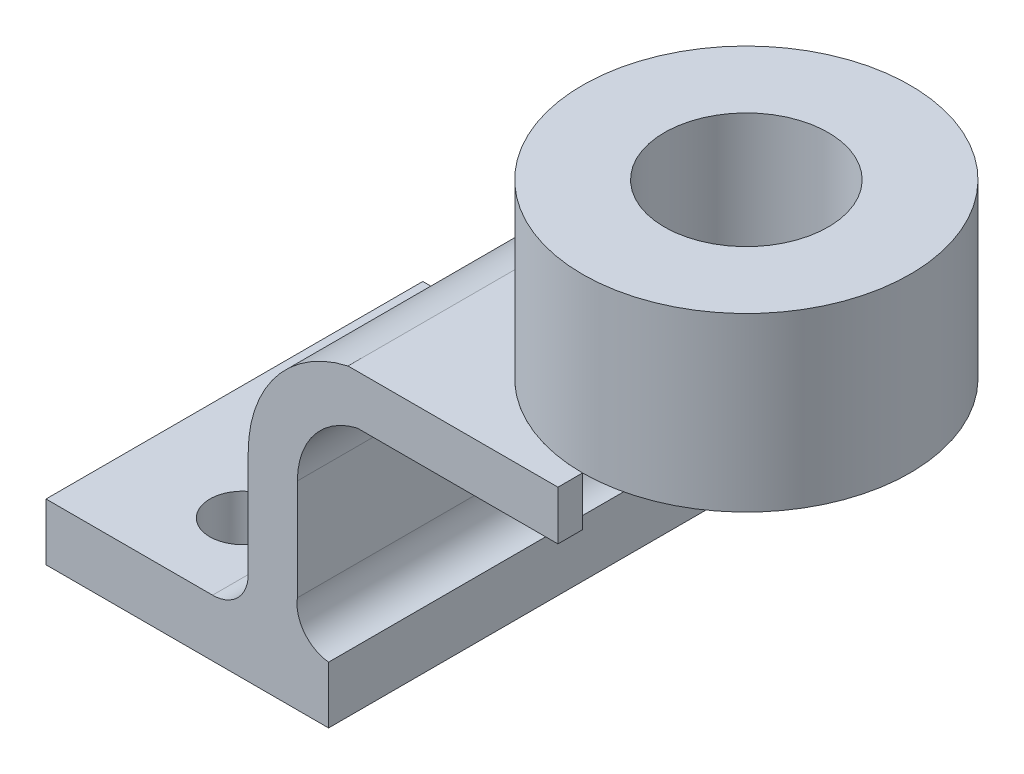
from build123d import *

# Parameters (mm, degrees)
BOSS_EXTRUDE4_DEPTH      = 46
BOSS_EXTRUDE4_DEPTH_BACK = 46
BOSS_EXTRUDE7_DEPTH      = 42
BOSS_EXTRUDE7_DEPTH_BACK = 18
SKETCH4_R                = 20
CUT_EXTRUDE6_DEPTH       = 49
SKETCH3_R                = 8
CUT_EXTRUDE7_DEPTH       = 49


with BuildPart() as part:
    # Sketch1 → Boss-Extrude4 (new, two sides: drawn at the far end of the back side and taken through both)
    with BuildSketch(Plane.XY.offset(-BOSS_EXTRUDE4_DEPTH_BACK)):
        with BuildLine():
            Line((-83.24312297, -25.479382505), (-14.24312297, -25.479382505))
            Line((-14.24312297, -25.479382505), (-14.24312297, -11.557434351))
            ThreePointArc((-14.24312297, -11.557434351), (-20.155754423, -8.289544205), (-21.866972477, -1.754251597))
            Line((-21.866972477, -1.754251597), (-21.866972477, 22.947247706))
            ThreePointArc((-21.866972477, 22.947247706), (-17.780772391, 34.725544597), (-7.278061456, 41.442565649))
            Line((-7.278061456, 41.442565649), (87.990821984, 41.442565649))
            Line((87.990821984, 41.442565649), (87.990821984, 53.442590356))
            Line((87.990821984, 53.442590356), (-9.495412844, 53.442590356))
            ThreePointArc((-9.495412844, 53.442590356), (-27.025554627, 42.466077348), (-33.866972477, 22.947247706))
            Line((-33.866972477, 22.947247706), (-33.866972477, -2.851012333))
            ThreePointArc((-33.866972477, -2.851012333), (-36.417024446, -9.007382382), (-42.573394495, -11.557434351))
            Line((-42.573394495, -11.557434351), (-83.24312297, -11.557434351))
            Line((-83.24312297, -11.557434351), (-83.24312297, -25.479382505))
        make_face()
    extrude(amount=BOSS_EXTRUDE4_DEPTH + BOSS_EXTRUDE4_DEPTH_BACK)

    # Sketch4 → Boss-Extrude7 (add, two sides: drawn at the far end of the back side and taken through both)
    with BuildSketch(Plane(origin=(0, 53.442590356, 0), x_dir=(1, 0, 0), z_dir=(0, 1, 0)).offset(-BOSS_EXTRUDE7_DEPTH_BACK)):
        with BuildLine():
            ThreePointArc((41.75687703, -40), (70.041148278, -28.284271247), (81.75687703, 0))
            ThreePointArc((81.75687703, 0), (70.041148278, 28.284271247), (41.75687703, 40))
            ThreePointArc((41.75687703, 40), (1.75687703, 0), (41.75687703, -40))
        make_face()
        with Locations((41.75687703, 0)):
            Circle(SKETCH4_R, mode=Mode.SUBTRACT)
    extrude(amount=BOSS_EXTRUDE7_DEPTH + BOSS_EXTRUDE7_DEPTH_BACK)

    # Sketch5 → Cut-Extrude6 (cut)
    with BuildSketch(Plane(origin=(0, 53.442590356, 0), x_dir=(1, 0, 0), z_dir=(0, 1, 0))):
        with BuildLine():
            Line((41.75687703, 46), (41.75687703, 40))
            ThreePointArc((41.75687703, 40), (1.75687703, 0), (41.75687703, -40))
            Line((41.75687703, -40), (41.75687703, -46))
            Line((41.75687703, -46), (87.990821984, -46))
            Line((87.990821984, -46), (87.990821984, 46))
            Line((87.990821984, 46), (41.75687703, 46))
        make_face()
    extrude(amount=-CUT_EXTRUDE6_DEPTH, mode=Mode.SUBTRACT)


with BuildPart() as cut_extrude6_piece_1:
    # of the separate pieces the step leaves, piece 1, a body of its own (cut_extrude6_pieces)
    add(part.part.solids().sort_by_distance((-42.573394495, -11.557434351, 46))[0])

    # Sketch3 → Cut-Extrude7 (cut)
    with BuildSketch(Plane(origin=(0, -11.557434351, 0), x_dir=(1, 0, 0), z_dir=(0, 1, 0))):
        with Locations((-55.24312297, 26)):
            Circle(SKETCH3_R)
        with Locations((-55.24312297, -26)):
            Circle(SKETCH3_R)
    extrude(amount=-CUT_EXTRUDE7_DEPTH, mode=Mode.SUBTRACT)


with BuildPart() as cut_extrude6_piece_2:
    # of the separate pieces the step leaves, piece 2, a body of its own (cut_extrude6_pieces)
    add(part.part.solids().sort_by_distance((41.75687703, 95.442590356, -40))[0])


solid = Compound([cut_extrude6_piece_1.part, cut_extrude6_piece_2.part])
